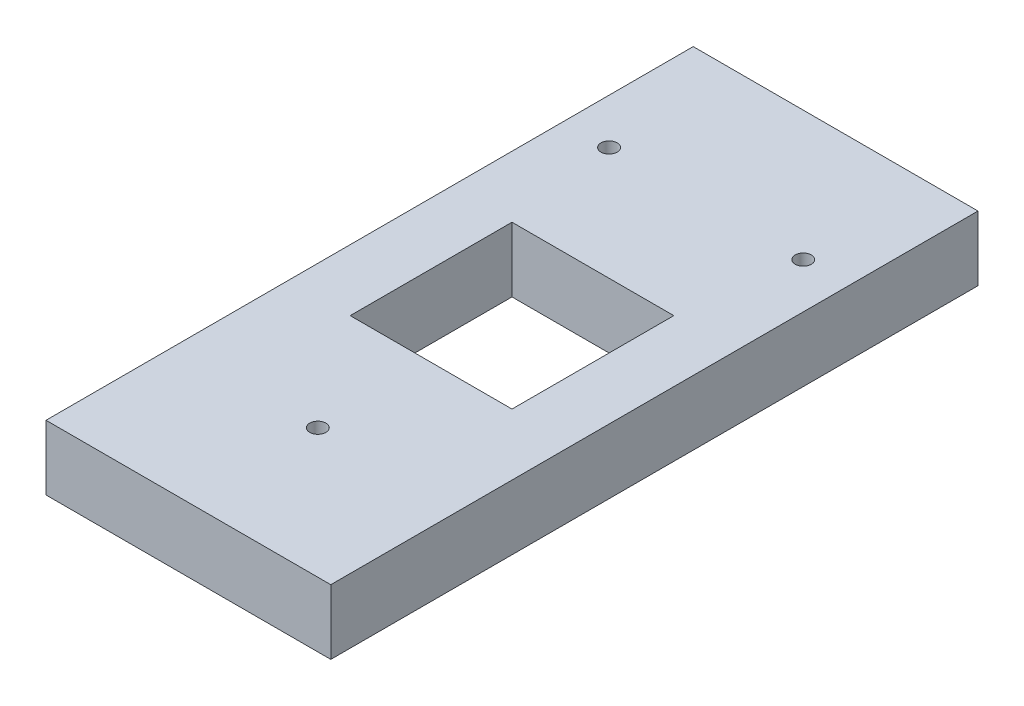
from build123d import *

# Parameters (mm, degrees)
SKETCH1_W           = 111.76
SKETCH1_H           = 254
BOSS_EXTRUDE1_DEPTH = 12.7
SKETCH2_W           = 63.5
SKETCH2_H           = 63.5
CUT_EXTRUDE1_DEPTH  = 25.4
CUT_EXTRUDE2_REACH  = 27.4
SKETCH3_R           = 3.175


with BuildPart() as part:
    # Sketch1 → Boss-Extrude1 (new body, symmetric)
    with BuildSketch(Plane(origin=(0, 0, 0), x_dir=(1, 0, 0), z_dir=(0, 1, 0))):
        Rectangle(SKETCH1_W, SKETCH1_H)
    extrude(amount=BOSS_EXTRUDE1_DEPTH, both=True)

    # Sketch2 → Cut-Extrude1 (cut)
    with BuildSketch(Plane(origin=(0, 12.7, 0), x_dir=(1, 0, 0), z_dir=(0, 1, 0))):
        Rectangle(SKETCH2_W, SKETCH2_H)
    extrude(amount=-CUT_EXTRUDE1_DEPTH, mode=Mode.SUBTRACT)

    # Sketch3 → Cut-Extrude2 (cut, up to next)
    with BuildSketch(Plane(origin=(0, 12.7, 0), x_dir=(1, 0, 0), z_dir=(0, 1, 0)), mode=Mode.PRIVATE) as cut_extrude2_sk1:
        with Locations((0, -76.2)):
            Circle(SKETCH3_R)
    cut_extrude2_tool1 = extrude(cut_extrude2_sk1.sketch, amount=-CUT_EXTRUDE2_REACH, mode=Mode.PRIVATE) & part.part
    add(cut_extrude2_tool1.solids().sort_by_distance((0, 12.7, 76.2))[0], mode=Mode.SUBTRACT)
    # Sketch3 → Cut-Extrude2 (cut, up to next)
    with BuildSketch(Plane(origin=(0, 12.7, 0), x_dir=(1, 0, 0), z_dir=(0, 1, 0)), mode=Mode.PRIVATE) as cut_extrude2_sk2:
        with Locations((38.1, 76.2)):
            Circle(SKETCH3_R)
    cut_extrude2_tool2 = extrude(cut_extrude2_sk2.sketch, amount=-CUT_EXTRUDE2_REACH, mode=Mode.PRIVATE) & part.part
    add(cut_extrude2_tool2.solids().sort_by_distance((38.1, 12.7, -76.2))[0], mode=Mode.SUBTRACT)
    # Sketch3 → Cut-Extrude2 (cut, up to next)
    with BuildSketch(Plane(origin=(0, 12.7, 0), x_dir=(1, 0, 0), z_dir=(0, 1, 0)), mode=Mode.PRIVATE) as cut_extrude2_sk3:
        with Locations((-38.1, 76.2)):
            Circle(SKETCH3_R)
    cut_extrude2_tool3 = extrude(cut_extrude2_sk3.sketch, amount=-CUT_EXTRUDE2_REACH, mode=Mode.PRIVATE) & part.part
    add(cut_extrude2_tool3.solids().sort_by_distance((-38.1, 12.7, -76.2))[0], mode=Mode.SUBTRACT)


solid = part.part
